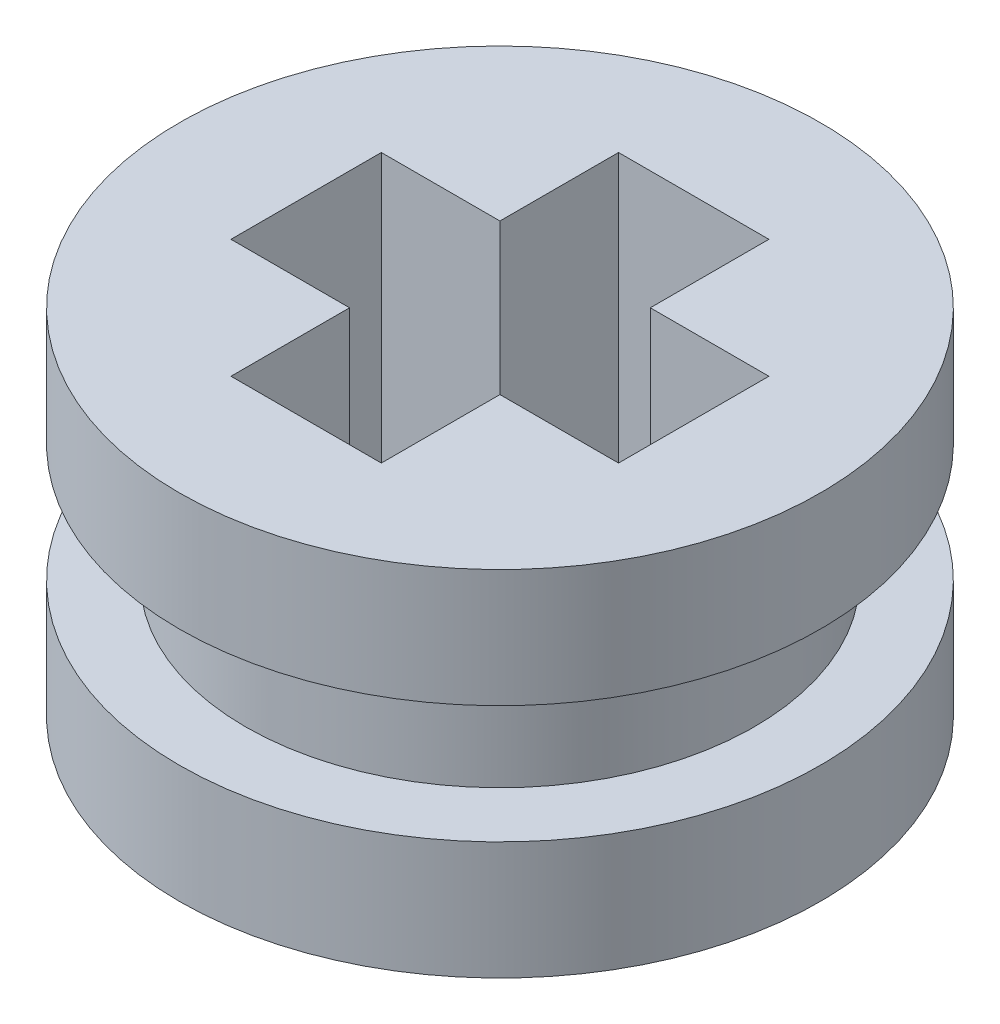
from build123d import *

# Parameters (mm, degrees)
SKETCH2_R           = 3.625
BOSS_EXTRUDE1_DEPTH = 1.33333333
SKETCH6_R           = 2.875
BOSS_EXTRUDE2_DEPTH = 1.33333333
SKETCH7_R           = 3.625
BOSS_EXTRUDE3_DEPTH = 1.33333333
CUT_EXTRUDE1_DEPTH  = 4.99999999


with BuildPart() as part:
    # Sketch2 → Boss-Extrude1 (new body)
    with BuildSketch(Plane(origin=(0, 0, 0), x_dir=(1, 0, 0), z_dir=(0, 1, 0))):
        Circle(SKETCH2_R)
    extrude(amount=BOSS_EXTRUDE1_DEPTH)

    # Sketch6 → Boss-Extrude2 (add)
    with BuildSketch(Plane(origin=(0, 1.33333333, 0), x_dir=(1, 0, 0), z_dir=(0, 1, 0))):
        Circle(SKETCH6_R)
    extrude(amount=BOSS_EXTRUDE2_DEPTH)

    # Sketch7 → Boss-Extrude3 (add)
    with BuildSketch(Plane(origin=(0, 2.66666666, 0), x_dir=(1, 0, 0), z_dir=(0, 1, 0))):
        Circle(SKETCH7_R)
    extrude(amount=BOSS_EXTRUDE3_DEPTH)

    # Sketch8 → Cut-Extrude1 (cut, through all)
    with BuildSketch(Plane(origin=(0, 3.99999999, 0), x_dir=(1, 0, 0), z_dir=(0, 1, 0))):
        Polygon((-0.85, 0.85), (-0.85, 2.19089023), (0.85, 2.19089023), (0.85, 0.85), (2.19089023, 0.85), (2.19089023, -0.85), (0.85, -0.85), (0.85, -2.19089023), (-0.85, -2.19089023), (-0.85, -0.85), (-2.19089023, -0.85), (-2.19089023, 0.85), align=None)
    extrude(amount=-CUT_EXTRUDE1_DEPTH, mode=Mode.SUBTRACT)


solid = part.part
